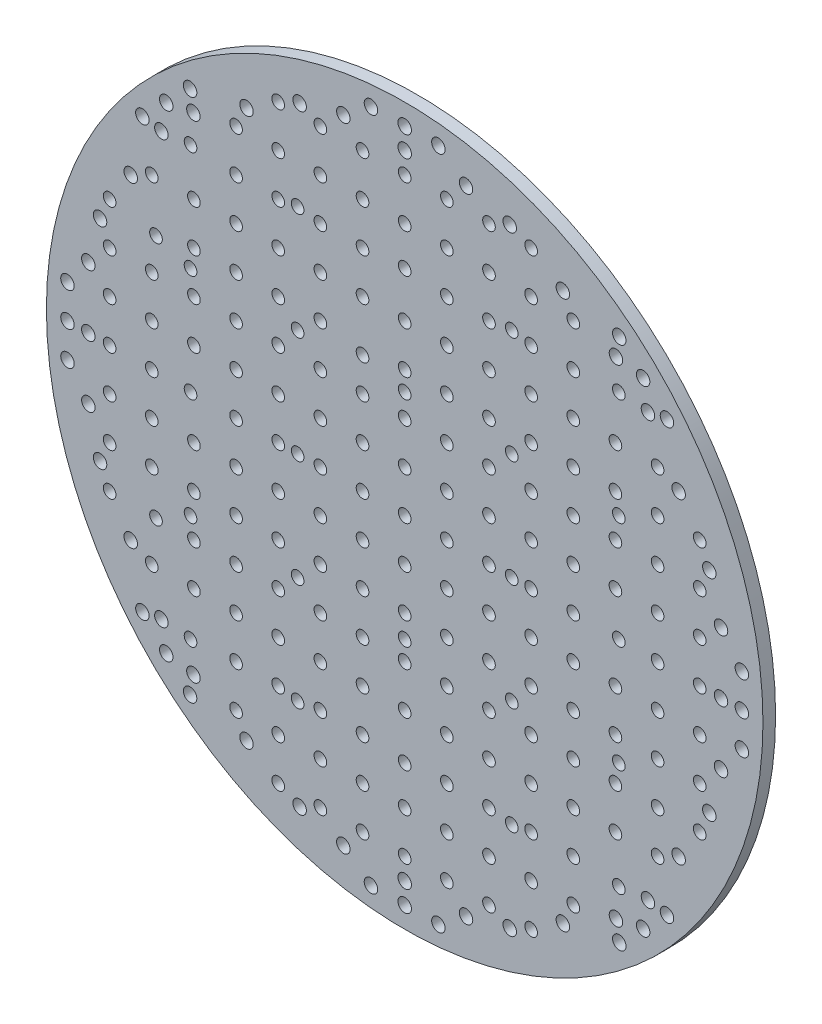
from build123d import *

# Parameters (mm, degrees)
SKETCH_1_R      = 85
SKETCH_1_R_2    = 1.5
SKETCH_1_R_3    = 1.6
EXTRUDE_1_DEPTH = 3


with BuildPart() as part:
    # Эскиз1 → Бобышка-Вытянуть1 (new body)
    with BuildSketch(Plane.XY):
        Circle(SKETCH_1_R)
        with Locations((-10, 28)):
            Circle(SKETCH_1_R_2, mode=Mode.SUBTRACT)
        with Locations((-59, 28)):
            Circle(SKETCH_1_R_2, mode=Mode.SUBTRACT)
        with Locations((-59, -30)):
            Circle(SKETCH_1_R_2, mode=Mode.SUBTRACT)
        with Locations((-10, -30)):
            Circle(SKETCH_1_R_2, mode=Mode.SUBTRACT)
        with Locations((37.525, 64.995206554)):
            Circle(SKETCH_1_R_3, mode=Mode.SUBTRACT)
        with Locations((-50.125669625, -57.720206554)):
            Circle(SKETCH_1_R_3, mode=Mode.SUBTRACT)
        with Locations((-57.720206554, 50.125669625)):
            Circle(SKETCH_1_R_3, mode=Mode.SUBTRACT)
        with Locations((-24.924330375, 72.270206554)):
            Circle(SKETCH_1_R_3, mode=Mode.SUBTRACT)
        with Locations((-75.05, 0)):
            Circle(SKETCH_1_R_3, mode=Mode.SUBTRACT)
        with Locations((50.125669625, -57.720206554)):
            Circle(SKETCH_1_R_3, mode=Mode.SUBTRACT)
        with Locations((-72.270206554, 24.924330375)):
            Circle(SKETCH_1_R_3, mode=Mode.SUBTRACT)
        with Locations((64.995206554, -37.525)):
            Circle(SKETCH_1_R_3, mode=Mode.SUBTRACT)
        with Locations((50.125669625, 57.720206554)):
            Circle(SKETCH_1_R_3, mode=Mode.SUBTRACT)
        with Locations((37.525, -64.995206554)):
            Circle(SKETCH_1_R_3, mode=Mode.SUBTRACT)
        with Locations((-14.55, 75.05)):
            Circle(SKETCH_1_R_3, mode=Mode.SUBTRACT)
        with Locations((-72.270206554, -24.924330375)):
            Circle(SKETCH_1_R_3, mode=Mode.SUBTRACT)
        with Locations((24.924330375, -72.270206554)):
            Circle(SKETCH_1_R_3, mode=Mode.SUBTRACT)
        with Locations((14.55, -75.05)):
            Circle(SKETCH_1_R_3, mode=Mode.SUBTRACT)
        with Locations((64.995206554, 37.525)):
            Circle(SKETCH_1_R_3, mode=Mode.SUBTRACT)
        with Locations((-37.525, -64.995206554)):
            Circle(SKETCH_1_R_3, mode=Mode.SUBTRACT)
        with Locations((-75.05, 14.55)):
            Circle(SKETCH_1_R_3, mode=Mode.SUBTRACT)
        with Locations((72.270206554, 24.924330375)):
            Circle(SKETCH_1_R_3, mode=Mode.SUBTRACT)
        with Locations((0, -75.05)):
            Circle(SKETCH_1_R_3, mode=Mode.SUBTRACT)
        with Locations((-75.05, -14.55)):
            Circle(SKETCH_1_R_3, mode=Mode.SUBTRACT)
        with Locations((-64.995206554, 37.525)):
            Circle(SKETCH_1_R_3, mode=Mode.SUBTRACT)
        with Locations((-57.720206554, -50.125669625)):
            Circle(SKETCH_1_R_3, mode=Mode.SUBTRACT)
        with Locations((57.720206554, 50.125669625)):
            Circle(SKETCH_1_R_3, mode=Mode.SUBTRACT)
        with Locations((-14.55, -75.05)):
            Circle(SKETCH_1_R_3, mode=Mode.SUBTRACT)
        with Locations((75.05, 14.55)):
            Circle(SKETCH_1_R_3, mode=Mode.SUBTRACT)
        with Locations((24.924330375, 72.270206554)):
            Circle(SKETCH_1_R_3, mode=Mode.SUBTRACT)
        with Locations((-50.125669625, 57.720206554)):
            Circle(SKETCH_1_R_3, mode=Mode.SUBTRACT)
        with Locations((-24.924330375, -72.270206554)):
            Circle(SKETCH_1_R_3, mode=Mode.SUBTRACT)
        with Locations((-64.995206554, -37.525)):
            Circle(SKETCH_1_R_3, mode=Mode.SUBTRACT)
        with Locations((75.05, -14.55)):
            Circle(SKETCH_1_R_3, mode=Mode.SUBTRACT)
        with Locations((14.55, 75.05)):
            Circle(SKETCH_1_R_3, mode=Mode.SUBTRACT)
        with Locations((0, 75.05)):
            Circle(SKETCH_1_R_3, mode=Mode.SUBTRACT)
        with Locations((57.720206554, -50.125669625)):
            Circle(SKETCH_1_R_3, mode=Mode.SUBTRACT)
        with Locations((75.05, 0)):
            Circle(SKETCH_1_R_3, mode=Mode.SUBTRACT)
        with Locations((72.270206554, -24.924330375)):
            Circle(SKETCH_1_R_3, mode=Mode.SUBTRACT)
        with Locations((-37.525, 64.995206554)):
            Circle(SKETCH_1_R_3, mode=Mode.SUBTRACT)
        Circle(SKETCH_1_R_2, mode=Mode.SUBTRACT)
        with Locations((25.4, 0)):
            Circle(SKETCH_1_R_2, mode=Mode.SUBTRACT)
        with Locations((0, 25.4)):
            Circle(SKETCH_1_R_2, mode=Mode.SUBTRACT)
        with Locations((25.4, 25.4)):
            Circle(SKETCH_1_R_2, mode=Mode.SUBTRACT)
        with Locations((50.8, 0)):
            Circle(SKETCH_1_R_2, mode=Mode.SUBTRACT)
        with Locations((50.8, 25.4)):
            Circle(SKETCH_1_R_2, mode=Mode.SUBTRACT)
        with Locations((0, 50.8)):
            Circle(SKETCH_1_R_2, mode=Mode.SUBTRACT)
        with Locations((25.4, 50.8)):
            Circle(SKETCH_1_R_2, mode=Mode.SUBTRACT)
        with Locations((50.8, 50.8)):
            Circle(SKETCH_1_R_2, mode=Mode.SUBTRACT)
        with Locations((0, -25.4)):
            Circle(SKETCH_1_R_2, mode=Mode.SUBTRACT)
        with Locations((25.4, -25.4)):
            Circle(SKETCH_1_R_2, mode=Mode.SUBTRACT)
        with Locations((50.8, -25.4)):
            Circle(SKETCH_1_R_2, mode=Mode.SUBTRACT)
        with Locations((0, -50.8)):
            Circle(SKETCH_1_R_2, mode=Mode.SUBTRACT)
        with Locations((25.4, -50.8)):
            Circle(SKETCH_1_R_2, mode=Mode.SUBTRACT)
        with Locations((50.8, -50.8)):
            Circle(SKETCH_1_R_2, mode=Mode.SUBTRACT)
        with Locations((-25.4, 0)):
            Circle(SKETCH_1_R_2, mode=Mode.SUBTRACT)
        with Locations((-25.4, 25.4)):
            Circle(SKETCH_1_R_2, mode=Mode.SUBTRACT)
        with Locations((-50.8, 0)):
            Circle(SKETCH_1_R_2, mode=Mode.SUBTRACT)
        with Locations((-50.8, 25.4)):
            Circle(SKETCH_1_R_2, mode=Mode.SUBTRACT)
        with Locations((-25.4, 50.8)):
            Circle(SKETCH_1_R_2, mode=Mode.SUBTRACT)
        with Locations((-50.8, 50.8)):
            Circle(SKETCH_1_R_2, mode=Mode.SUBTRACT)
        with Locations((-25.4, -25.4)):
            Circle(SKETCH_1_R_2, mode=Mode.SUBTRACT)
        with Locations((-50.8, -25.4)):
            Circle(SKETCH_1_R_2, mode=Mode.SUBTRACT)
        with Locations((-25.4, -50.8)):
            Circle(SKETCH_1_R_2, mode=Mode.SUBTRACT)
        with Locations((-50.8, -50.8)):
            Circle(SKETCH_1_R_2, mode=Mode.SUBTRACT)
        with Locations((0, -80)):
            Circle(SKETCH_1_R_3, mode=Mode.SUBTRACT)
        with Locations((-8, -80)):
            Circle(SKETCH_1_R_3, mode=Mode.SUBTRACT)
        with Locations((8, -80)):
            Circle(SKETCH_1_R_3, mode=Mode.SUBTRACT)
        with Locations((0, 10)):
            Circle(SKETCH_1_R_2, mode=Mode.SUBTRACT)
        with Locations((-10, 0)):
            Circle(SKETCH_1_R_2, mode=Mode.SUBTRACT)
        with Locations((-10, 10)):
            Circle(SKETCH_1_R_2, mode=Mode.SUBTRACT)
        with Locations((-10, 20)):
            Circle(SKETCH_1_R_2, mode=Mode.SUBTRACT)
        with Locations((-10, 40)):
            Circle(SKETCH_1_R_2, mode=Mode.SUBTRACT)
        with Locations((0, 20)):
            Circle(SKETCH_1_R_2, mode=Mode.SUBTRACT)
        with Locations((0, 30)):
            Circle(SKETCH_1_R_2, mode=Mode.SUBTRACT)
        with Locations((0, 40)):
            Circle(SKETCH_1_R_2, mode=Mode.SUBTRACT)
        with Locations((-10, 50)):
            Circle(SKETCH_1_R_2, mode=Mode.SUBTRACT)
        with Locations((-10, 60)):
            Circle(SKETCH_1_R_2, mode=Mode.SUBTRACT)
        with Locations((-10, 70)):
            Circle(SKETCH_1_R_2, mode=Mode.SUBTRACT)
        with Locations((0, 60)):
            Circle(SKETCH_1_R_2, mode=Mode.SUBTRACT)
        with Locations((0, 70)):
            Circle(SKETCH_1_R_2, mode=Mode.SUBTRACT)
        with Locations((-20, 0)):
            Circle(SKETCH_1_R_2, mode=Mode.SUBTRACT)
        with Locations((-20, 10)):
            Circle(SKETCH_1_R_2, mode=Mode.SUBTRACT)
        with Locations((-20, 20)):
            Circle(SKETCH_1_R_2, mode=Mode.SUBTRACT)
        with Locations((-20, 30)):
            Circle(SKETCH_1_R_2, mode=Mode.SUBTRACT)
        with Locations((-20, 40)):
            Circle(SKETCH_1_R_2, mode=Mode.SUBTRACT)
        with Locations((-20, 50)):
            Circle(SKETCH_1_R_2, mode=Mode.SUBTRACT)
        with Locations((-20, 60)):
            Circle(SKETCH_1_R_2, mode=Mode.SUBTRACT)
        with Locations((-20, 70)):
            Circle(SKETCH_1_R_2, mode=Mode.SUBTRACT)
        with Locations((-30, 0)):
            Circle(SKETCH_1_R_2, mode=Mode.SUBTRACT)
        with Locations((-30, 10)):
            Circle(SKETCH_1_R_2, mode=Mode.SUBTRACT)
        with Locations((-30, 20)):
            Circle(SKETCH_1_R_2, mode=Mode.SUBTRACT)
        with Locations((-30, 30)):
            Circle(SKETCH_1_R_2, mode=Mode.SUBTRACT)
        with Locations((-30, 40)):
            Circle(SKETCH_1_R_2, mode=Mode.SUBTRACT)
        with Locations((-30, 50)):
            Circle(SKETCH_1_R_2, mode=Mode.SUBTRACT)
        with Locations((-30, 60)):
            Circle(SKETCH_1_R_2, mode=Mode.SUBTRACT)
        with Locations((-30, 70)):
            Circle(SKETCH_1_R_2, mode=Mode.SUBTRACT)
        with Locations((-40, 0)):
            Circle(SKETCH_1_R_2, mode=Mode.SUBTRACT)
        with Locations((-40, 10)):
            Circle(SKETCH_1_R_2, mode=Mode.SUBTRACT)
        with Locations((-40, 20)):
            Circle(SKETCH_1_R_2, mode=Mode.SUBTRACT)
        with Locations((-40, 30)):
            Circle(SKETCH_1_R_2, mode=Mode.SUBTRACT)
        with Locations((-40, 40)):
            Circle(SKETCH_1_R_2, mode=Mode.SUBTRACT)
        with Locations((-40, 50)):
            Circle(SKETCH_1_R_2, mode=Mode.SUBTRACT)
        with Locations((-40, 60)):
            Circle(SKETCH_1_R_2, mode=Mode.SUBTRACT)
        with Locations((-50, 10)):
            Circle(SKETCH_1_R_2, mode=Mode.SUBTRACT)
        with Locations((-50, 20)):
            Circle(SKETCH_1_R_2, mode=Mode.SUBTRACT)
        with Locations((-50, 30)):
            Circle(SKETCH_1_R_2, mode=Mode.SUBTRACT)
        with Locations((-50, 40)):
            Circle(SKETCH_1_R_2, mode=Mode.SUBTRACT)
        with Locations((-60, 0)):
            Circle(SKETCH_1_R_2, mode=Mode.SUBTRACT)
        with Locations((-60, 10)):
            Circle(SKETCH_1_R_2, mode=Mode.SUBTRACT)
        with Locations((-60, 20)):
            Circle(SKETCH_1_R_2, mode=Mode.SUBTRACT)
        with Locations((-60, 40)):
            Circle(SKETCH_1_R_2, mode=Mode.SUBTRACT)
        with Locations((-70, 0)):
            Circle(SKETCH_1_R_2, mode=Mode.SUBTRACT)
        with Locations((-70, 10)):
            Circle(SKETCH_1_R_2, mode=Mode.SUBTRACT)
        with Locations((-70, 20)):
            Circle(SKETCH_1_R_2, mode=Mode.SUBTRACT)
        with Locations((-70, 30)):
            Circle(SKETCH_1_R_2, mode=Mode.SUBTRACT)
        with Locations((10, 10)):
            Circle(SKETCH_1_R_2, mode=Mode.SUBTRACT)
        with Locations((10, 20)):
            Circle(SKETCH_1_R_2, mode=Mode.SUBTRACT)
        with Locations((10, 30)):
            Circle(SKETCH_1_R_2, mode=Mode.SUBTRACT)
        with Locations((10, 40)):
            Circle(SKETCH_1_R_2, mode=Mode.SUBTRACT)
        with Locations((10, 50)):
            Circle(SKETCH_1_R_2, mode=Mode.SUBTRACT)
        with Locations((10, 60)):
            Circle(SKETCH_1_R_2, mode=Mode.SUBTRACT)
        with Locations((10, 70)):
            Circle(SKETCH_1_R_2, mode=Mode.SUBTRACT)
        with Locations((20, 10)):
            Circle(SKETCH_1_R_2, mode=Mode.SUBTRACT)
        with Locations((20, 20)):
            Circle(SKETCH_1_R_2, mode=Mode.SUBTRACT)
        with Locations((20, 30)):
            Circle(SKETCH_1_R_2, mode=Mode.SUBTRACT)
        with Locations((20, 40)):
            Circle(SKETCH_1_R_2, mode=Mode.SUBTRACT)
        with Locations((20, 50)):
            Circle(SKETCH_1_R_2, mode=Mode.SUBTRACT)
        with Locations((20, 60)):
            Circle(SKETCH_1_R_2, mode=Mode.SUBTRACT)
        with Locations((20, 70)):
            Circle(SKETCH_1_R_2, mode=Mode.SUBTRACT)
        with Locations((30, 10)):
            Circle(SKETCH_1_R_2, mode=Mode.SUBTRACT)
        with Locations((30, 20)):
            Circle(SKETCH_1_R_2, mode=Mode.SUBTRACT)
        with Locations((30, 30)):
            Circle(SKETCH_1_R_2, mode=Mode.SUBTRACT)
        with Locations((30, 40)):
            Circle(SKETCH_1_R_2, mode=Mode.SUBTRACT)
        with Locations((30, 50)):
            Circle(SKETCH_1_R_2, mode=Mode.SUBTRACT)
        with Locations((30, 60)):
            Circle(SKETCH_1_R_2, mode=Mode.SUBTRACT)
        with Locations((30, 70)):
            Circle(SKETCH_1_R_2, mode=Mode.SUBTRACT)
        with Locations((40, 10)):
            Circle(SKETCH_1_R_2, mode=Mode.SUBTRACT)
        with Locations((40, 20)):
            Circle(SKETCH_1_R_2, mode=Mode.SUBTRACT)
        with Locations((40, 30)):
            Circle(SKETCH_1_R_2, mode=Mode.SUBTRACT)
        with Locations((40, 40)):
            Circle(SKETCH_1_R_2, mode=Mode.SUBTRACT)
        with Locations((40, 50)):
            Circle(SKETCH_1_R_2, mode=Mode.SUBTRACT)
        with Locations((40, 60)):
            Circle(SKETCH_1_R_2, mode=Mode.SUBTRACT)
        with Locations((50, 10)):
            Circle(SKETCH_1_R_2, mode=Mode.SUBTRACT)
        with Locations((50, 20)):
            Circle(SKETCH_1_R_2, mode=Mode.SUBTRACT)
        with Locations((50, 30)):
            Circle(SKETCH_1_R_2, mode=Mode.SUBTRACT)
        with Locations((50, 40)):
            Circle(SKETCH_1_R_2, mode=Mode.SUBTRACT)
        with Locations((60, 10)):
            Circle(SKETCH_1_R_2, mode=Mode.SUBTRACT)
        with Locations((60, 20)):
            Circle(SKETCH_1_R_2, mode=Mode.SUBTRACT)
        with Locations((60, 30)):
            Circle(SKETCH_1_R_2, mode=Mode.SUBTRACT)
        with Locations((60, 40)):
            Circle(SKETCH_1_R_2, mode=Mode.SUBTRACT)
        with Locations((70, 10)):
            Circle(SKETCH_1_R_2, mode=Mode.SUBTRACT)
        with Locations((70, 20)):
            Circle(SKETCH_1_R_2, mode=Mode.SUBTRACT)
        with Locations((70, 30)):
            Circle(SKETCH_1_R_2, mode=Mode.SUBTRACT)
        with Locations((10, 0)):
            Circle(SKETCH_1_R_2, mode=Mode.SUBTRACT)
        with Locations((20, 0)):
            Circle(SKETCH_1_R_2, mode=Mode.SUBTRACT)
        with Locations((30, 0)):
            Circle(SKETCH_1_R_2, mode=Mode.SUBTRACT)
        with Locations((40, 0)):
            Circle(SKETCH_1_R_2, mode=Mode.SUBTRACT)
        with Locations((60, 0)):
            Circle(SKETCH_1_R_2, mode=Mode.SUBTRACT)
        with Locations((70, 0)):
            Circle(SKETCH_1_R_2, mode=Mode.SUBTRACT)
        with Locations((0, -10)):
            Circle(SKETCH_1_R_2, mode=Mode.SUBTRACT)
        with Locations((-10, -10)):
            Circle(SKETCH_1_R_2, mode=Mode.SUBTRACT)
        with Locations((-10, -20)):
            Circle(SKETCH_1_R_2, mode=Mode.SUBTRACT)
        with Locations((-10, -40)):
            Circle(SKETCH_1_R_2, mode=Mode.SUBTRACT)
        with Locations((0, -20)):
            Circle(SKETCH_1_R_2, mode=Mode.SUBTRACT)
        with Locations((0, -30)):
            Circle(SKETCH_1_R_2, mode=Mode.SUBTRACT)
        with Locations((0, -40)):
            Circle(SKETCH_1_R_2, mode=Mode.SUBTRACT)
        with Locations((-10, -50)):
            Circle(SKETCH_1_R_2, mode=Mode.SUBTRACT)
        with Locations((-10, -60)):
            Circle(SKETCH_1_R_2, mode=Mode.SUBTRACT)
        with Locations((-10, -70)):
            Circle(SKETCH_1_R_2, mode=Mode.SUBTRACT)
        with Locations((0, -60)):
            Circle(SKETCH_1_R_2, mode=Mode.SUBTRACT)
        with Locations((0, -70)):
            Circle(SKETCH_1_R_2, mode=Mode.SUBTRACT)
        with Locations((-20, -10)):
            Circle(SKETCH_1_R_2, mode=Mode.SUBTRACT)
        with Locations((-20, -20)):
            Circle(SKETCH_1_R_2, mode=Mode.SUBTRACT)
        with Locations((-20, -30)):
            Circle(SKETCH_1_R_2, mode=Mode.SUBTRACT)
        with Locations((-20, -40)):
            Circle(SKETCH_1_R_2, mode=Mode.SUBTRACT)
        with Locations((-20, -50)):
            Circle(SKETCH_1_R_2, mode=Mode.SUBTRACT)
        with Locations((-20, -60)):
            Circle(SKETCH_1_R_2, mode=Mode.SUBTRACT)
        with Locations((-20, -70)):
            Circle(SKETCH_1_R_2, mode=Mode.SUBTRACT)
        with Locations((-30, -10)):
            Circle(SKETCH_1_R_2, mode=Mode.SUBTRACT)
        with Locations((-30, -20)):
            Circle(SKETCH_1_R_2, mode=Mode.SUBTRACT)
        with Locations((-30, -30)):
            Circle(SKETCH_1_R_2, mode=Mode.SUBTRACT)
        with Locations((-30, -40)):
            Circle(SKETCH_1_R_2, mode=Mode.SUBTRACT)
        with Locations((-30, -50)):
            Circle(SKETCH_1_R_2, mode=Mode.SUBTRACT)
        with Locations((-30, -60)):
            Circle(SKETCH_1_R_2, mode=Mode.SUBTRACT)
        with Locations((-30, -70)):
            Circle(SKETCH_1_R_2, mode=Mode.SUBTRACT)
        with Locations((-40, -10)):
            Circle(SKETCH_1_R_2, mode=Mode.SUBTRACT)
        with Locations((-40, -20)):
            Circle(SKETCH_1_R_2, mode=Mode.SUBTRACT)
        with Locations((-40, -30)):
            Circle(SKETCH_1_R_2, mode=Mode.SUBTRACT)
        with Locations((-40, -40)):
            Circle(SKETCH_1_R_2, mode=Mode.SUBTRACT)
        with Locations((-40, -50)):
            Circle(SKETCH_1_R_2, mode=Mode.SUBTRACT)
        with Locations((-40, -60)):
            Circle(SKETCH_1_R_2, mode=Mode.SUBTRACT)
        with Locations((-50, -10)):
            Circle(SKETCH_1_R_2, mode=Mode.SUBTRACT)
        with Locations((-50, -20)):
            Circle(SKETCH_1_R_2, mode=Mode.SUBTRACT)
        with Locations((-50, -30)):
            Circle(SKETCH_1_R_2, mode=Mode.SUBTRACT)
        with Locations((-50, -40)):
            Circle(SKETCH_1_R_2, mode=Mode.SUBTRACT)
        with Locations((-60, -10)):
            Circle(SKETCH_1_R_2, mode=Mode.SUBTRACT)
        with Locations((-60, -20)):
            Circle(SKETCH_1_R_2, mode=Mode.SUBTRACT)
        with Locations((-60, -40)):
            Circle(SKETCH_1_R_2, mode=Mode.SUBTRACT)
        with Locations((-70, -10)):
            Circle(SKETCH_1_R_2, mode=Mode.SUBTRACT)
        with Locations((-70, -20)):
            Circle(SKETCH_1_R_2, mode=Mode.SUBTRACT)
        with Locations((-70, -30)):
            Circle(SKETCH_1_R_2, mode=Mode.SUBTRACT)
        with Locations((10, -10)):
            Circle(SKETCH_1_R_2, mode=Mode.SUBTRACT)
        with Locations((10, -20)):
            Circle(SKETCH_1_R_2, mode=Mode.SUBTRACT)
        with Locations((10, -30)):
            Circle(SKETCH_1_R_2, mode=Mode.SUBTRACT)
        with Locations((10, -40)):
            Circle(SKETCH_1_R_2, mode=Mode.SUBTRACT)
        with Locations((10, -50)):
            Circle(SKETCH_1_R_2, mode=Mode.SUBTRACT)
        with Locations((10, -60)):
            Circle(SKETCH_1_R_2, mode=Mode.SUBTRACT)
        with Locations((10, -70)):
            Circle(SKETCH_1_R_2, mode=Mode.SUBTRACT)
        with Locations((20, -10)):
            Circle(SKETCH_1_R_2, mode=Mode.SUBTRACT)
        with Locations((20, -20)):
            Circle(SKETCH_1_R_2, mode=Mode.SUBTRACT)
        with Locations((20, -30)):
            Circle(SKETCH_1_R_2, mode=Mode.SUBTRACT)
        with Locations((20, -40)):
            Circle(SKETCH_1_R_2, mode=Mode.SUBTRACT)
        with Locations((20, -50)):
            Circle(SKETCH_1_R_2, mode=Mode.SUBTRACT)
        with Locations((20, -60)):
            Circle(SKETCH_1_R_2, mode=Mode.SUBTRACT)
        with Locations((20, -70)):
            Circle(SKETCH_1_R_2, mode=Mode.SUBTRACT)
        with Locations((30, -10)):
            Circle(SKETCH_1_R_2, mode=Mode.SUBTRACT)
        with Locations((30, -20)):
            Circle(SKETCH_1_R_2, mode=Mode.SUBTRACT)
        with Locations((30, -30)):
            Circle(SKETCH_1_R_2, mode=Mode.SUBTRACT)
        with Locations((30, -40)):
            Circle(SKETCH_1_R_2, mode=Mode.SUBTRACT)
        with Locations((30, -50)):
            Circle(SKETCH_1_R_2, mode=Mode.SUBTRACT)
        with Locations((30, -60)):
            Circle(SKETCH_1_R_2, mode=Mode.SUBTRACT)
        with Locations((30, -70)):
            Circle(SKETCH_1_R_2, mode=Mode.SUBTRACT)
        with Locations((40, -10)):
            Circle(SKETCH_1_R_2, mode=Mode.SUBTRACT)
        with Locations((40, -20)):
            Circle(SKETCH_1_R_2, mode=Mode.SUBTRACT)
        with Locations((40, -30)):
            Circle(SKETCH_1_R_2, mode=Mode.SUBTRACT)
        with Locations((40, -40)):
            Circle(SKETCH_1_R_2, mode=Mode.SUBTRACT)
        with Locations((40, -50)):
            Circle(SKETCH_1_R_2, mode=Mode.SUBTRACT)
        with Locations((40, -60)):
            Circle(SKETCH_1_R_2, mode=Mode.SUBTRACT)
        with Locations((50, -10)):
            Circle(SKETCH_1_R_2, mode=Mode.SUBTRACT)
        with Locations((50, -20)):
            Circle(SKETCH_1_R_2, mode=Mode.SUBTRACT)
        with Locations((50, -30)):
            Circle(SKETCH_1_R_2, mode=Mode.SUBTRACT)
        with Locations((50, -40)):
            Circle(SKETCH_1_R_2, mode=Mode.SUBTRACT)
        with Locations((60, -10)):
            Circle(SKETCH_1_R_2, mode=Mode.SUBTRACT)
        with Locations((60, -20)):
            Circle(SKETCH_1_R_2, mode=Mode.SUBTRACT)
        with Locations((60, -30)):
            Circle(SKETCH_1_R_2, mode=Mode.SUBTRACT)
        with Locations((60, -40)):
            Circle(SKETCH_1_R_2, mode=Mode.SUBTRACT)
        with Locations((70, -10)):
            Circle(SKETCH_1_R_2, mode=Mode.SUBTRACT)
        with Locations((70, -20)):
            Circle(SKETCH_1_R_2, mode=Mode.SUBTRACT)
        with Locations((70, -30)):
            Circle(SKETCH_1_R_2, mode=Mode.SUBTRACT)
        with Locations((56.568542495, -56.568542495)):
            Circle(SKETCH_1_R_3, mode=Mode.SUBTRACT)
        with Locations((50.911688245, -62.225396744)):
            Circle(SKETCH_1_R_3, mode=Mode.SUBTRACT)
        with Locations((62.225396744, -50.911688245)):
            Circle(SKETCH_1_R_3, mode=Mode.SUBTRACT)
        with Locations((80, 0)):
            Circle(SKETCH_1_R_3, mode=Mode.SUBTRACT)
        with Locations((80, -8)):
            Circle(SKETCH_1_R_3, mode=Mode.SUBTRACT)
        with Locations((80, 8)):
            Circle(SKETCH_1_R_3, mode=Mode.SUBTRACT)
        with Locations((56.568542495, 56.568542495)):
            Circle(SKETCH_1_R_3, mode=Mode.SUBTRACT)
        with Locations((62.225396744, 50.911688245)):
            Circle(SKETCH_1_R_3, mode=Mode.SUBTRACT)
        with Locations((50.911688245, 62.225396744)):
            Circle(SKETCH_1_R_3, mode=Mode.SUBTRACT)
        with Locations((0, 80)):
            Circle(SKETCH_1_R_3, mode=Mode.SUBTRACT)
        with Locations((8, 80)):
            Circle(SKETCH_1_R_3, mode=Mode.SUBTRACT)
        with Locations((-8, 80)):
            Circle(SKETCH_1_R_3, mode=Mode.SUBTRACT)
        with Locations((-56.568542495, 56.568542495)):
            Circle(SKETCH_1_R_3, mode=Mode.SUBTRACT)
        with Locations((-50.911688245, 62.225396744)):
            Circle(SKETCH_1_R_3, mode=Mode.SUBTRACT)
        with Locations((-62.225396744, 50.911688245)):
            Circle(SKETCH_1_R_3, mode=Mode.SUBTRACT)
        with Locations((-80, 0)):
            Circle(SKETCH_1_R_3, mode=Mode.SUBTRACT)
        with Locations((-80, 8)):
            Circle(SKETCH_1_R_3, mode=Mode.SUBTRACT)
        with Locations((-80, -8)):
            Circle(SKETCH_1_R_3, mode=Mode.SUBTRACT)
        with Locations((-56.568542495, -56.568542495)):
            Circle(SKETCH_1_R_3, mode=Mode.SUBTRACT)
        with Locations((-62.225396744, -50.911688245)):
            Circle(SKETCH_1_R_3, mode=Mode.SUBTRACT)
        with Locations((-50.911688245, -62.225396744)):
            Circle(SKETCH_1_R_3, mode=Mode.SUBTRACT)
    extrude(amount=EXTRUDE_1_DEPTH)


solid = part.part
